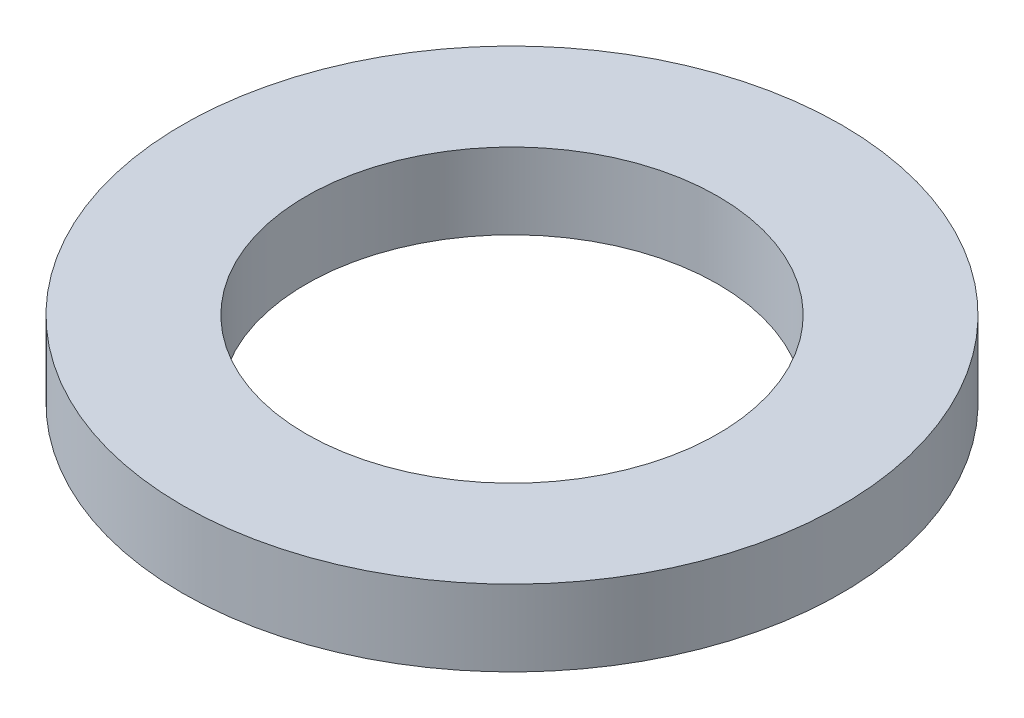
from build123d import *

# Parameters (mm, degrees)
SKETCH1_R           = 26.65
SKETCH1_R_2         = 16.65
BOSS_EXTRUDE1_DEPTH = 6.15


with BuildPart() as part:
    # Sketch1 → Boss-Extrude1 (new body)
    with BuildSketch(Plane(origin=(0, 0, 0), x_dir=(1, 0, 0), z_dir=(0, 1, 0))):
        Circle(SKETCH1_R)
        Circle(SKETCH1_R_2, mode=Mode.SUBTRACT)
    extrude(amount=BOSS_EXTRUDE1_DEPTH)


solid = part.part
